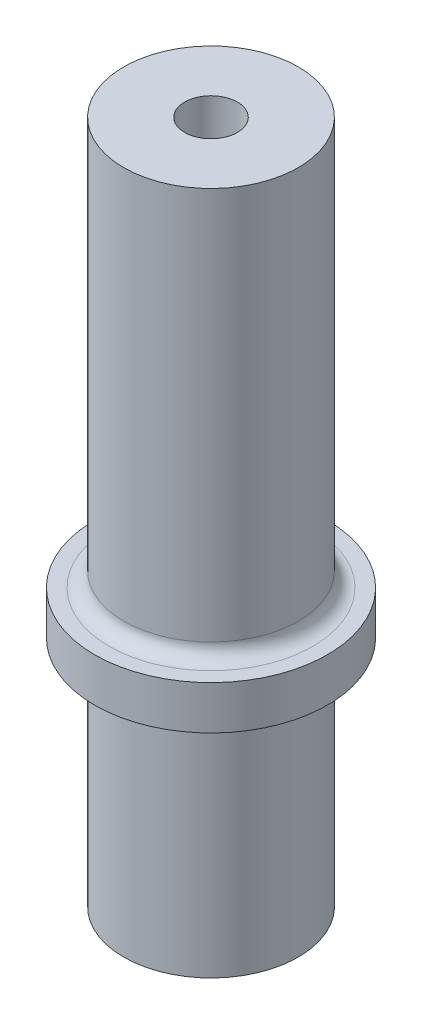
from build123d import *

# Parameters (mm, degrees)
F_1_2_20_TAPPED_HOLE1_D     = 11.50874
F_1_2_20_TAPPED_HOLE1_DEPTH = 29.21
F_1_2_20_TAPPED_HOLE1_TIP   = 3.45757432
FILLET1_R                   = 3.175


with BuildPart() as part:
    # Sketch1 → Revolve2 (revolve)
    with BuildSketch(Plane.XY):
        Polygon((-25.4, -2.966632853), (-25.4, 6.558367147), (-19.05, 6.558367147), (-19.05, 95.458367147), (0, 95.458367147), (0, 0), (0, -53.766632853), (-19.05, -53.766632853), (-19.05, -2.966632853), align=None)
    revolve(axis=Axis((0, 95.458367147, 0), (0, -1, 0)))

    # 1/2-20 Tapped Hole1
    with Locations(Plane.ZX.offset(95.458367147)):
        with Locations((0, 0)):
            Hole(F_1_2_20_TAPPED_HOLE1_D / 2, depth=F_1_2_20_TAPPED_HOLE1_DEPTH)
            with Locations((0, 0, -(F_1_2_20_TAPPED_HOLE1_DEPTH + F_1_2_20_TAPPED_HOLE1_TIP / 2))):  # 118° drill point
                Cone(0, F_1_2_20_TAPPED_HOLE1_D / 2, F_1_2_20_TAPPED_HOLE1_TIP, mode=Mode.SUBTRACT)

    # Fillet1
    fillet1_edges = [part.edges().sort_by_distance(p)[0] for p in [
        (19.05, 6.558367147, 0),
        (19.05, -2.966632853, 0),
    ]]
    fillet(fillet1_edges, radius=FILLET1_R)


solid = part.part
